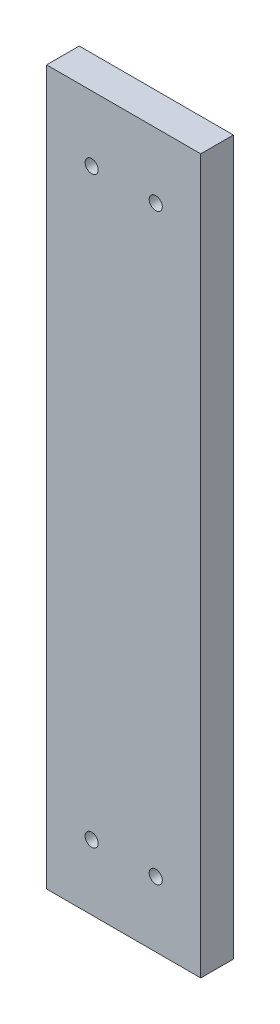
from build123d import *

# Parameters (mm, degrees)
SKETCH1_W               = 60
SKETCH1_H               = 12.7
BOSS_EXTRUDE1_DEPTH     = 277.876
F_1_4_20_TAPPED_HOLE1_D = 5.1054


with BuildPart() as part:
    # Sketch1 → Boss-Extrude1 (new body)
    with BuildSketch(Plane(origin=(0, 0, 0), x_dir=(1, 0, 0), z_dir=(0, 1, 0))):
        with Locations((30, 6.35)):
            Rectangle(SKETCH1_W, SKETCH1_H)
    extrude(amount=BOSS_EXTRUDE1_DEPTH)

    # 1/4-20 Tapped Hole1 (through all)
    with Locations(Plane(origin=(17.526, 252.476, 0), x_dir=(1, 0, 0), z_dir=(0, 0, 1))):
        with Locations((0, 0), (24.948, 0), (0, -227.076), (24.948, -227.076)):
            Hole(F_1_4_20_TAPPED_HOLE1_D / 2)


solid = part.part
